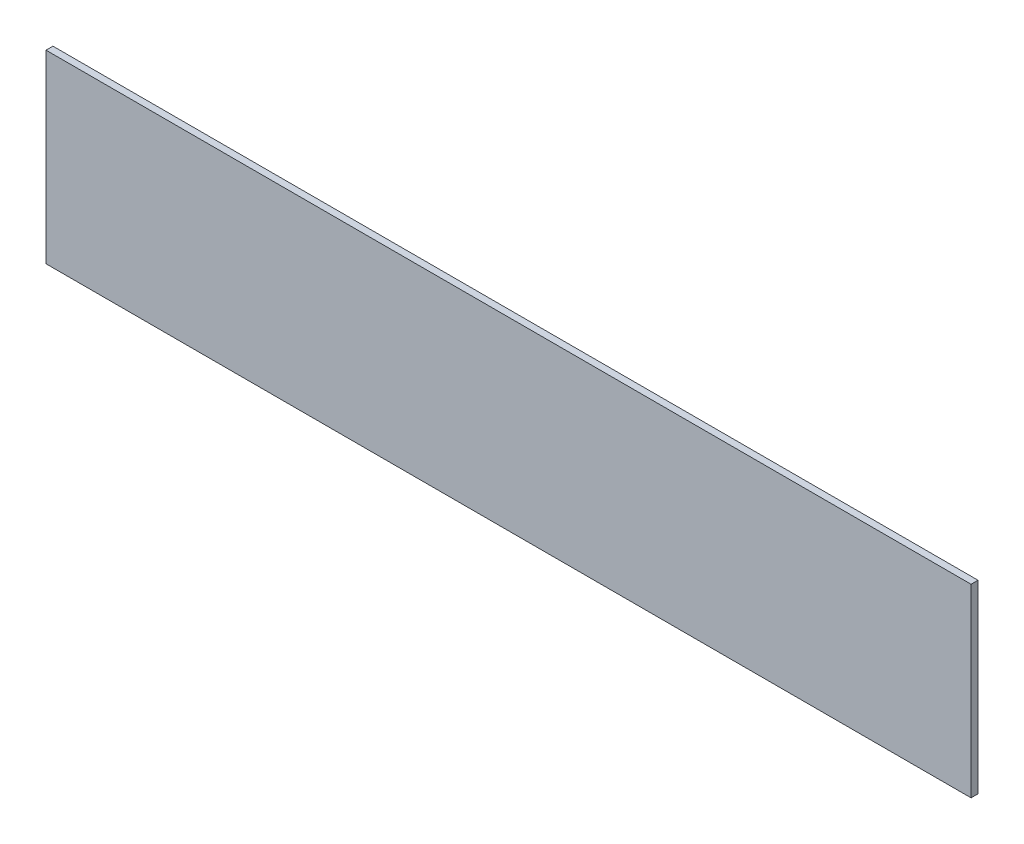
from build123d import *

# Parameters (mm, degrees)
SKETCH1_W           = 1270
SKETCH1_H           = 254
BOSS_EXTRUDE1_DEPTH = 9.525


with BuildPart() as part:
    # Sketch1 → Boss-Extrude1 (new body)
    with BuildSketch(Plane.XY):
        Rectangle(SKETCH1_W, SKETCH1_H)
    extrude(amount=BOSS_EXTRUDE1_DEPTH)


solid = part.part
